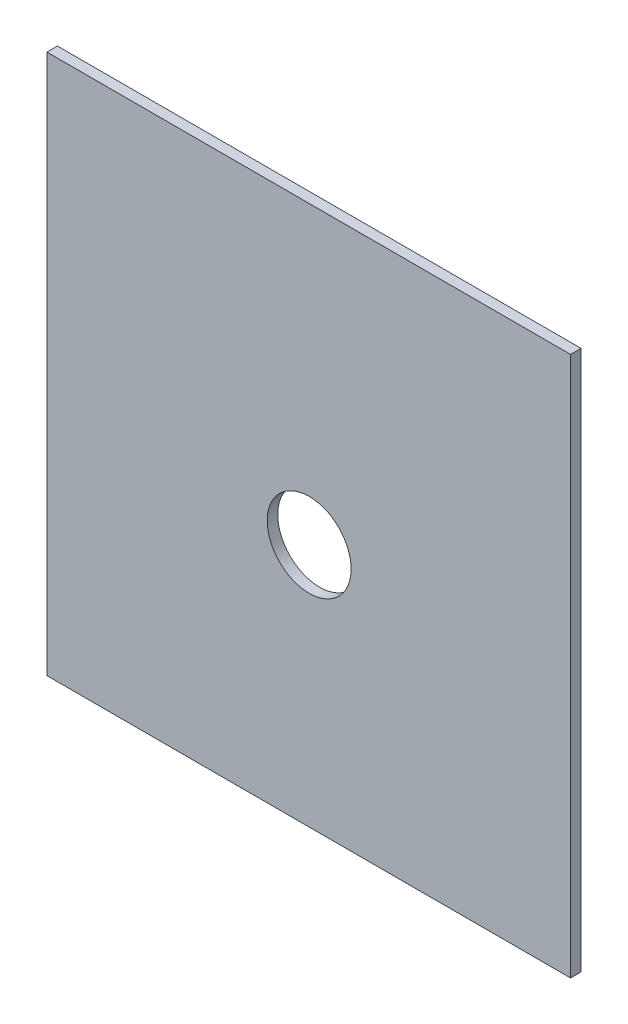
from build123d import *

# Parameters (mm, degrees)
SKETCH1_W           = 249.6
SKETCH1_H           = 257.4
BOSS_EXTRUDE1_DEPTH = 5
SKETCH2_R           = 20
CUT_EXTRUDE1_DEPTH  = 6


with BuildPart() as part:
    # Sketch1 → Boss-Extrude1 (new body)
    with BuildSketch(Plane.XY):
        with Locations((124.8, -128.7)):
            Rectangle(SKETCH1_W, SKETCH1_H)
    extrude(amount=BOSS_EXTRUDE1_DEPTH)

    # Sketch2 → Cut-Extrude1 (cut, through all)
    with BuildSketch(Plane.XY.offset(5)):
        with Locations((125, -140.910978413)):
            Circle(SKETCH2_R)
    extrude(amount=-CUT_EXTRUDE1_DEPTH, mode=Mode.SUBTRACT)


solid = part.part
